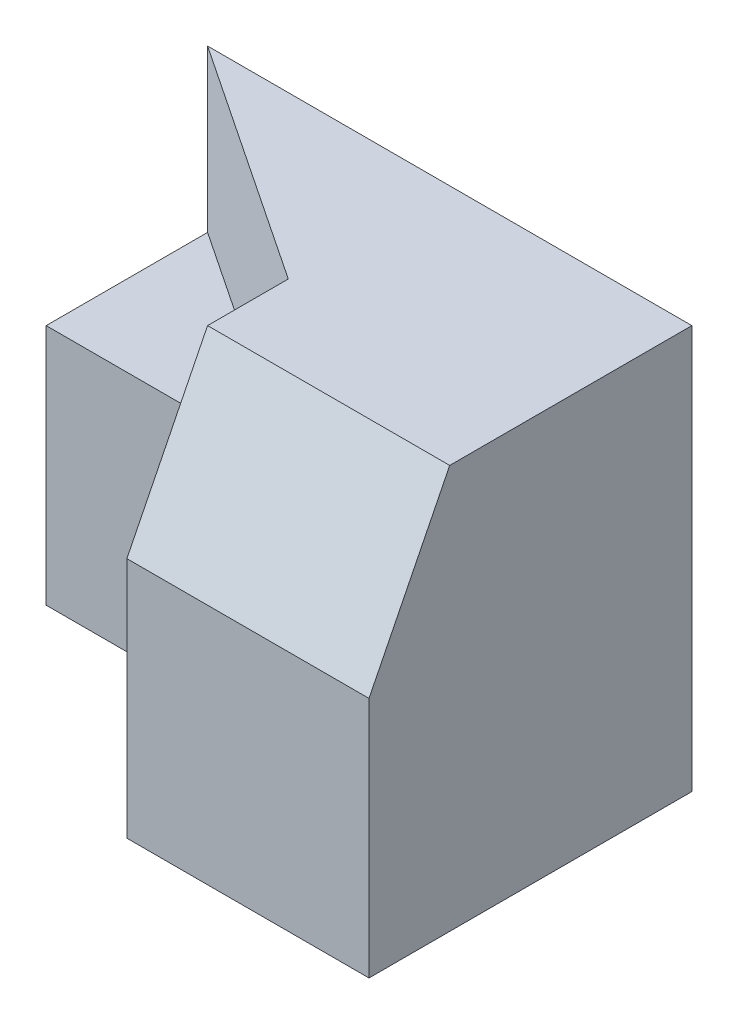
from build123d import *

# Parameters (mm, degrees)
SKETCH1_W           = 30
SKETCH1_H           = 25
BOSS_EXTRUDE1_DEPTH = 20
SKETCH2_W           = 15
SKETCH2_H           = 25
CUT_EXTRUDE1_DEPTH  = 10
CUT_EXTRUDE2_DEPTH  = 20
CUT_EXTRUDE3_DEPTH  = 10


with BuildPart() as part:
    # Sketch1 → Boss-Extrude1 (new body)
    with BuildSketch(Plane.XY):
        with Locations((15, 12.5)):
            Rectangle(SKETCH1_W, SKETCH1_H)
    extrude(amount=BOSS_EXTRUDE1_DEPTH)

    # Sketch2 → Cut-Extrude1 (cut)
    with BuildSketch(Plane.XY.offset(20)):
        with Locations((7.5, 12.5)):
            Rectangle(SKETCH2_W, SKETCH2_H)
    extrude(amount=-CUT_EXTRUDE1_DEPTH, mode=Mode.SUBTRACT)

    # Sketch3 → Cut-Extrude2 (cut)
    with BuildSketch(Plane.ZY.offset(-15)):
        Polygon((15, 25), (20, 15), (20, 25), align=None)
    extrude(amount=-CUT_EXTRUDE2_DEPTH, mode=Mode.SUBTRACT)

    # Sketch4 → Cut-Extrude3 (cut)
    with BuildSketch(Plane(origin=(0, 25, 0), x_dir=(1, 0, 0), z_dir=(0, 1, 0))):
        Polygon((15, -10), (0, 0), (0, -10), align=None)
    extrude(amount=-CUT_EXTRUDE3_DEPTH, mode=Mode.SUBTRACT)


solid = part.part
